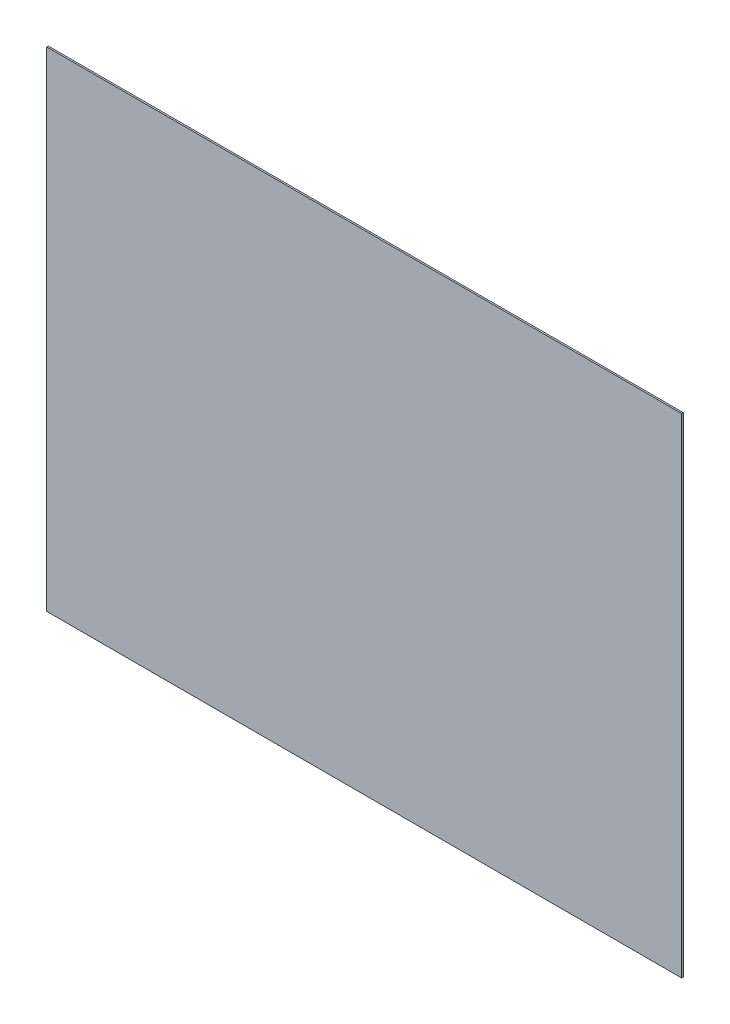
from build123d import *

# Parameters (mm, degrees)
EXTRUDE_1_DEPTH = 1


with BuildPart() as part:
    # 스케치1 → 보스-돌출1 (new body)
    with BuildSketch(Plane.XY):
        Polygon((0, 0), (400, 0), (400, 308), (330, 308), (20, 308), (0, 308), align=None)
    extrude(amount=EXTRUDE_1_DEPTH)


solid = part.part
